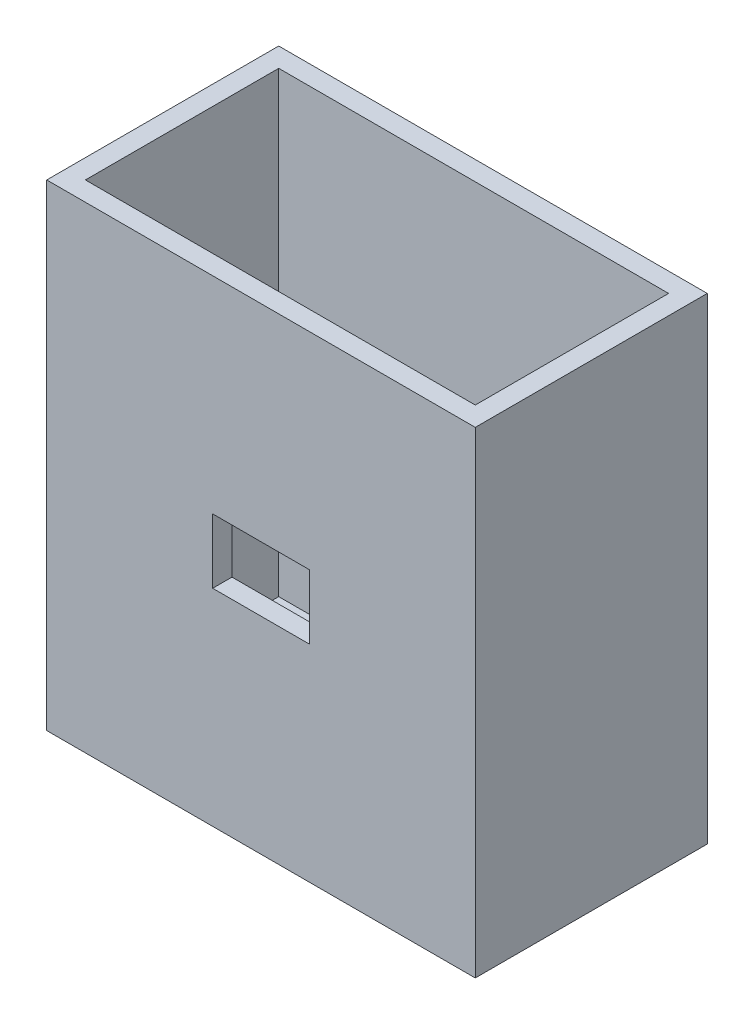
from build123d import *

# Parameters (mm, degrees)
SKETCH1_W           = 66.5
SKETCH1_H           = 36
SKETCH1_W_2         = 60.5
SKETCH1_H_2         = 30
BOSS_EXTRUDE1_DEPTH = 71
SKETCH1_3_W         = 66.5
SKETCH1_3_H         = 36
SKETCH1_3_W_2       = 60.5
SKETCH1_3_H_2       = 30
BOSS_EXTRUDE2_DEPTH = 3
CUT_EXTRUDE1_REACH  = 88.27
SKETCH2_W           = 15
SKETCH2_H           = 10
SKETCH4_W           = 1
SKETCH4_H           = 2
BOSS_EXTRUDE4_DEPTH = 15
CHAMFER1_SIZE       = 1
CUT_EXTRUDE2_DEPTH  = 1


with BuildPart() as part:
    # Sketch1 → Boss-Extrude1 (new body)
    with BuildSketch(Plane(origin=(0, 0, 0), x_dir=(1, 0, 0), z_dir=(0, 1, 0))):
        Rectangle(SKETCH1_W, SKETCH1_H)
        Rectangle(SKETCH1_W_2, SKETCH1_H_2, mode=Mode.SUBTRACT)
    extrude(amount=BOSS_EXTRUDE1_DEPTH)

    # Sketch1_3 → Boss-Extrude2 (add)
    with BuildSketch(Plane(origin=(0, 0, 0), x_dir=(1, 0, 0), z_dir=(0, 1, 0))):
        Rectangle(SKETCH1_3_W, SKETCH1_3_H)
        Rectangle(SKETCH1_3_W_2, SKETCH1_3_H_2, mode=Mode.SUBTRACT)
        Rectangle(SKETCH1_3_W_2, SKETCH1_3_H_2)
    extrude(amount=-BOSS_EXTRUDE2_DEPTH)

    # Sketch2 → Cut-Extrude1 (cut, up to next)
    with BuildSketch(Plane.XY.offset(18), mode=Mode.PRIVATE) as cut_extrude1_sk1:
        with Locations((0, 34)):
            Rectangle(SKETCH2_W, SKETCH2_H)
    cut_extrude1_tool1 = extrude(cut_extrude1_sk1.sketch, amount=-CUT_EXTRUDE1_REACH, mode=Mode.PRIVATE) & part.part
    add(cut_extrude1_tool1.solids().sort_by_distance((0, 34, 18))[0], mode=Mode.SUBTRACT)

    # Sketch4 → Boss-Extrude4 (add)
    with BuildSketch(Plane.ZY.offset(-7.5)):
        with Locations((14.5, 28)):
            Rectangle(SKETCH4_W, SKETCH4_H)
    extrude(amount=BOSS_EXTRUDE4_DEPTH)

    # Chamfer1
    chamfer1_edges = [part.edges().sort_by_distance(p)[0] for p in [
        (0, 29, 14),
    ]]
    chamfer(chamfer1_edges, length=CHAMFER1_SIZE)

    # Sketch5 → Cut-Extrude2 (cut)
    with BuildSketch(Plane(origin=(0, 0, -18), x_dir=(-1, 0, 0), z_dir=(0, 0, -1))):
        with BuildLine():
            Line((-2.638888889, 38.722222222), (-2.638888889, 39))
            Line((-2.638888889, 39), (2.5, 39))
            Line((2.5, 39), (2.5, 38.722222222))
            Line((2.5, 38.722222222), (2.172309028, 38.722222222))
            add(Edge.make_bspline(
                [(2.172309028, 38.722222222), (2.104184293, 38.720949678), (1.974513104, 38.718527469), (1.790231692, 38.689739833), (1.625736646, 38.644148981), (1.528628421, 38.595662221), (1.482204861, 38.572482639)],
                knots=[0, 0, 0, 0, 1.144467932, 2.17842344, 3.129177061, 4, 4, 4, 4], degree=3))
            add(Edge.make_bspline(
                [(1.482204861, 38.572482639), (1.451706337, 38.554084379), (1.390014843, 38.516868933), (1.310783803, 38.438036518), (1.243641581, 38.341940776), (1.209171954, 38.269240619), (1.19140625, 38.231770833)],
                knots=[0, 0, 0, 0, 0.93343552, 1.888125192, 2.911536119, 4, 4, 4, 4], degree=3))
            add(Edge.make_bspline(
                [(1.19140625, 38.231770833), (1.184350586, 38.214575185), (1.16854678, 38.176059078), (1.15557603, 38.106048651), (1.139091299, 38.020392262), (1.129876754, 37.915742203), (1.121221924, 37.794954741), (1.114101268, 37.656759716), (1.113522404, 37.501150705), (1.111942587, 37.391201064), (1.111111111, 37.333333333)],
                knots=[0, 0, 0, 0, 0.491143652, 1.100100526, 1.878201893, 2.802922625, 3.87869145, 5.087223688, 6.466973141, 8, 8, 8, 8], degree=3))
            Line((1.111111111, 37.333333333), (1.111111111, 30.666666667))
            add(Edge.make_bspline(
                [(1.111111111, 30.666666667), (1.111939588, 30.608075204), (1.113524957, 30.495954931), (1.114136618, 30.336734675), (1.121108982, 30.194912102), (1.130079845, 30.070534861), (1.138829557, 29.962956044), (1.156182735, 29.873070769), (1.16828298, 29.799419433), (1.195529243, 29.72563882), (1.240143315, 29.646586055), (1.312990851, 29.562040058), (1.405657276, 29.483796342), (1.517159605, 29.411555124), (1.650210211, 29.350190049), (1.805638269, 29.308289334), (1.981882259, 29.281860539), (2.106374028, 29.279191428), (2.172309028, 29.277777778)],
                knots=[0, 0, 0, 0, 1.353804055, 2.590631371, 3.678090953, 4.633038001, 5.472823534, 6.167945078, 6.748082955, 7.192141313, 7.977799851, 8.831603391, 9.756085287, 10.771283584, 11.893005217, 13.125761034, 14.477707027, 16, 16, 16, 16], degree=3))
            Line((2.172309028, 29.277777778), (2.5, 29.277777778))
            Line((2.5, 29.277777778), (2.5, 29))
            Line((2.5, 29), (-2.638888889, 29))
            Line((-2.638888889, 29), (-2.638888889, 29.277777778))
            Line((-2.638888889, 29.277777778), (-2.313368056, 29.277777778))
            add(Edge.make_bspline(
                [(-2.313368056, 29.277777778), (-2.245251066, 29.279076928), (-2.115594618, 29.281549779), (-1.931900868, 29.309888715), (-1.76838513, 29.356309608), (-1.671870984, 29.404385876), (-1.625434028, 29.427517361)],
                knots=[0, 0, 0, 0, 1.147815573, 2.184795468, 3.126629849, 4, 4, 4, 4], degree=3))
            add(Edge.make_bspline(
                [(-1.625434028, 29.427517361), (-1.594905814, 29.445892719), (-1.533154265, 29.483061837), (-1.454093177, 29.562557374), (-1.38462361, 29.657817078), (-1.348756572, 29.730709883), (-1.330295139, 29.768229167)],
                knots=[0, 0, 0, 0, 0.928829741, 1.878808762, 2.908183361, 4, 4, 4, 4], degree=3))
            add(Edge.make_bspline(
                [(-1.330295139, 29.768229167), (-1.323206914, 29.785418433), (-1.307060225, 29.82457489), (-1.295055162, 29.894793912), (-1.277647574, 29.980267632), (-1.268863248, 30.084275321), (-1.26000169, 30.205758881), (-1.253094282, 30.343969196), (-1.252369885, 30.49957111), (-1.250820734, 30.60879845), (-1.25, 30.666666667)],
                knots=[0, 0, 0, 0, 0.491154816, 1.118830903, 1.878082211, 2.802823963, 3.878617243, 5.106317376, 6.466938293, 8, 8, 8, 8], degree=3))
            Line((-1.25, 30.666666667), (-1.25, 37.333333333))
            add(Edge.make_bspline(
                [(-1.25, 37.333333333), (-1.250801761, 37.391926604), (-1.252336008, 37.504050339), (-1.253291766, 37.663247301), (-1.259177025, 37.805200537), (-1.271446326, 37.928690427), (-1.280582203, 38.036174276), (-1.295723919, 38.125982088), (-1.312405424, 38.198748616), (-1.338621653, 38.273308229), (-1.385613233, 38.351596892), (-1.455981361, 38.439521903), (-1.551157589, 38.515346585), (-1.661938741, 38.588028597), (-1.793960563, 38.650297433), (-1.948902922, 38.691613339), (-2.12438389, 38.71806089), (-2.248154932, 38.720786263), (-2.313368056, 38.722222222)],
                knots=[0, 0, 0, 0, 1.355372936, 2.593633572, 3.682353377, 4.639723862, 5.46383559, 6.176261324, 6.744401302, 7.188974265, 7.998347102, 8.842429006, 9.78074911, 10.797123889, 11.904961153, 13.139145573, 14.492658294, 16, 16, 16, 16], degree=3))
            Line((-2.313368056, 38.722222222), (-2.638888889, 38.722222222))
        make_face()
    extrude(amount=-CUT_EXTRUDE2_DEPTH, mode=Mode.SUBTRACT)


solid = part.part
